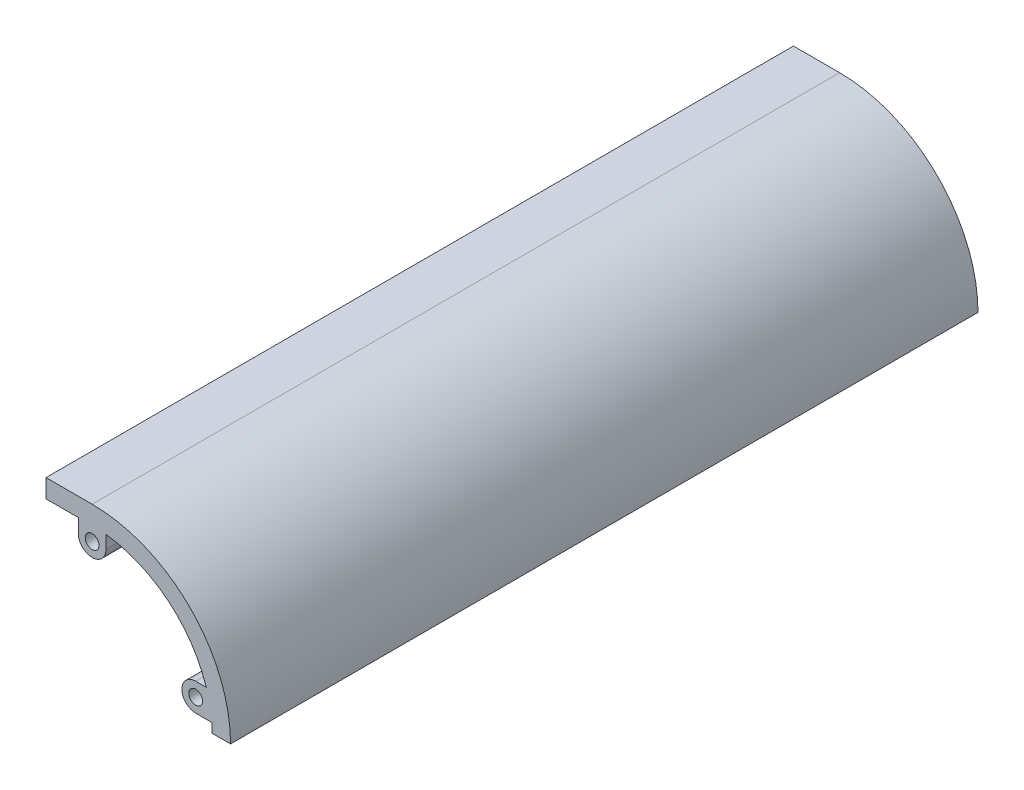
from build123d import *

# Parameters (mm, degrees)
SKETCH_1_R          = 1.5
EXTRUDE_1_DEPTH     = 162
CUT_EXTRUDE_1_DEPTH = 76


with BuildPart() as part:
    # 草图1 → 凸台-拉伸1 (new body)
    with BuildSketch(Plane.XY):
        with BuildLine():
            Line((-6.315789474, 9.394736842), (-6.315789474, 12.394736842))
            Line((-6.315789474, 12.394736842), (-13.315789474, 12.394736842))
            Line((-13.315789474, 12.394736842), (-13.315789474, 16.394736842))
            Line((-13.315789474, 16.394736842), (-3.315789474, 16.394736842))
            ThreePointArc((-3.315789474, 16.394736842), (17.897413962, 7.607940278), (26.684210526, -13.605263158))
            Line((26.684210526, -13.605263158), (22.684210526, -13.605263158))
            ThreePointArc((22.684210526, -13.605263158), (22.664944086, -12.604521591), (22.60717332, -11.605263158))
            Line((22.60717332, -11.605263158), (19.134154847, -11.605263158))
            ThreePointArc((19.134154847, -11.605263158), (16.134154847, -8.605263158), (19.134154847, -5.605263158))
            Line((19.134154847, -5.605263158), (21.42284428, -5.605263158))
            ThreePointArc((21.42284428, -5.605263158), (13.170646711, 6.499398539), (-0.315789474, 12.221079982))
            Line((-0.315789474, 12.221079982), (-0.315789474, 9.394736842))
            ThreePointArc((-0.315789474, 9.394736842), (-3.315789474, 6.394736842), (-6.315789474, 9.394736842))
        make_face()
        with Locations((-3.315789474, 9.394736842)):
            Circle(SKETCH_1_R, mode=Mode.SUBTRACT)
        with Locations((19.134154847, -8.605263158)):
            Circle(SKETCH_1_R, mode=Mode.SUBTRACT)
    extrude(amount=EXTRUDE_1_DEPTH)

    # 草图3 → 切除-拉伸1 (cut, symmetric)
    with BuildSketch(Plane.XY.offset(81)):
        with BuildLine():
            Line((-3.315789474, 12.394736842), (-13.315789474, 12.394736842))
            Line((-13.315789474, 12.394736842), (-18.728718327, 7.33373453))
            ThreePointArc((-18.728718327, 7.33373453), (4.795500809, -38.307630857), (-3.315789474, 12.394736842))
        make_face()
    extrude(amount=CUT_EXTRUDE_1_DEPTH, both=True, mode=Mode.SUBTRACT)


solid = part.part
